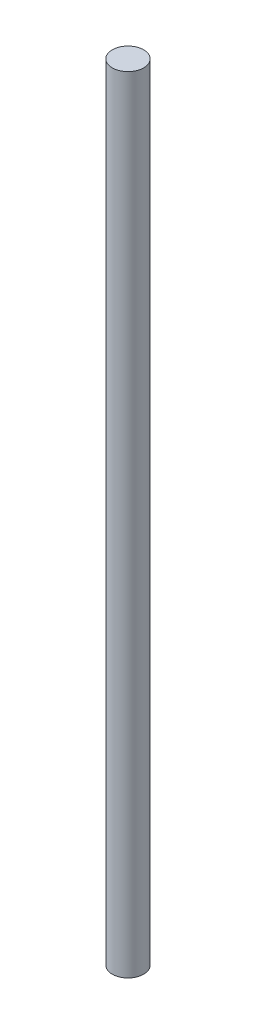
from build123d import *

# Parameters (mm, degrees)
SKETCH1_R           = 5
BOSS_EXTRUDE1_DEPTH = 250


with BuildPart() as part:
    # Sketch1 → Boss-Extrude1 (new body)
    with BuildSketch(Plane(origin=(0, 0, 0), x_dir=(1, 0, 0), z_dir=(0, 1, 0))):
        Circle(SKETCH1_R)
    extrude(amount=BOSS_EXTRUDE1_DEPTH)


solid = part.part
